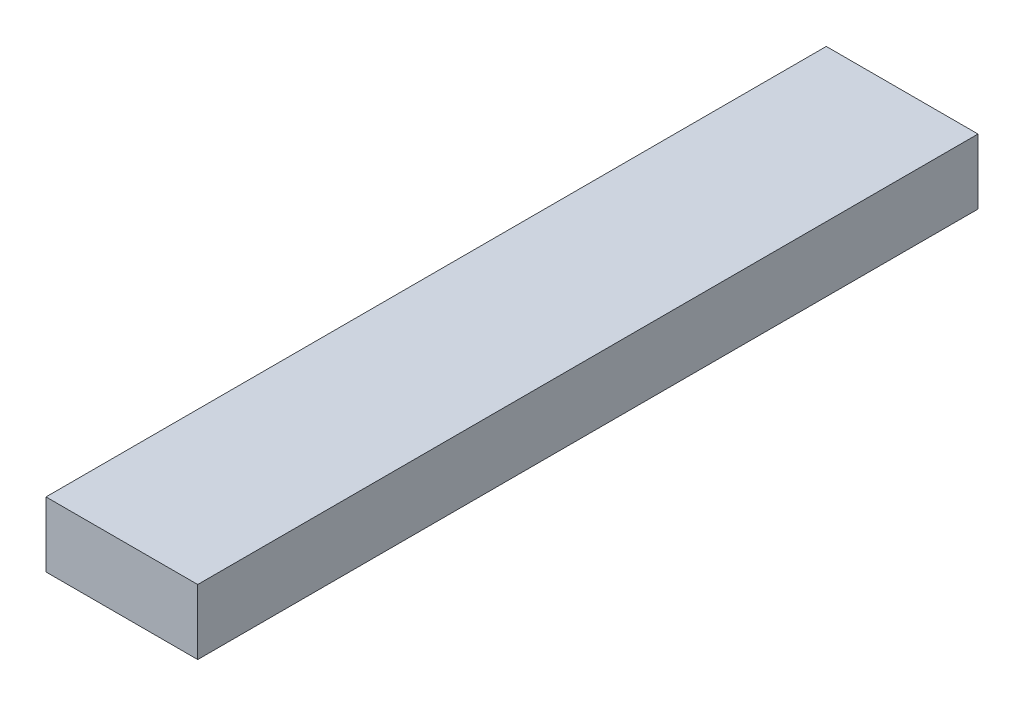
from build123d import *

# Parameters (mm, degrees)
SKETCH1_W           = 88.9
SKETCH1_H           = 38.1
BOSS_EXTRUDE1_DEPTH = 457.2


with BuildPart() as part:
    # Sketch1 → Boss-Extrude1 (new body)
    with BuildSketch(Plane.XY):
        with Locations((36.498798917, 7.326923077)):
            Rectangle(SKETCH1_W, SKETCH1_H)
    extrude(amount=BOSS_EXTRUDE1_DEPTH)


solid = part.part
